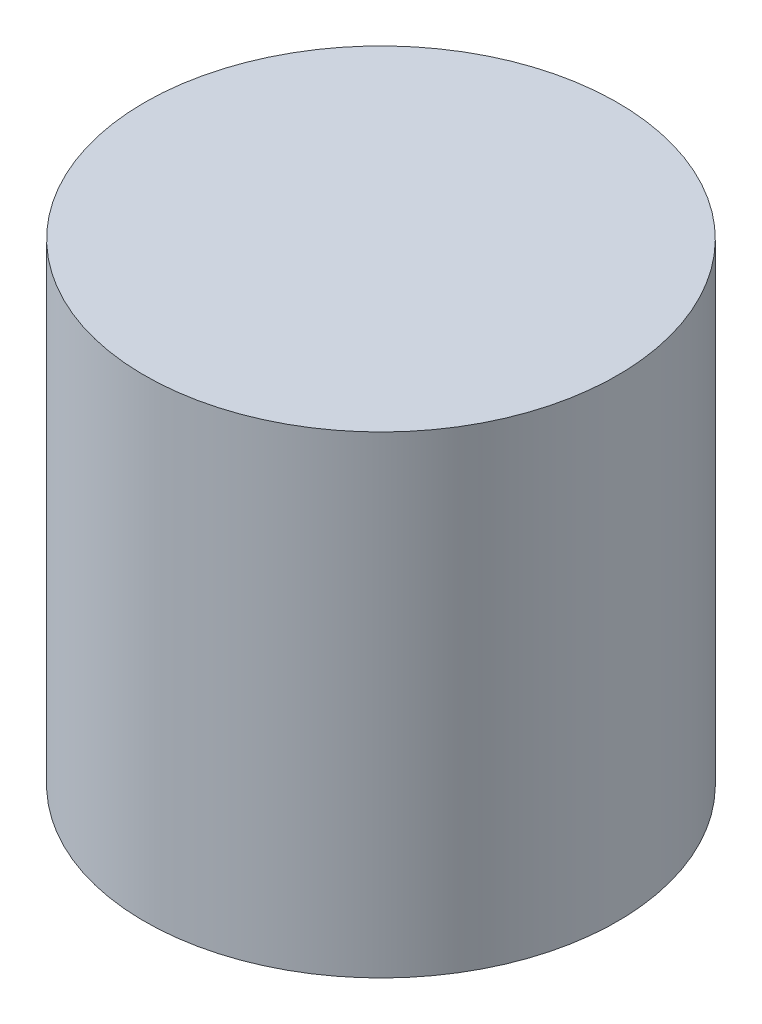
from build123d import *


with BuildPart() as part:
    # Sketch1 → Revolve1 (revolve)
    with BuildSketch(Plane.XY, mode=Mode.PRIVATE) as revolve1_sk:
        Polygon((50.8, 50.8), (0, 50.8), (0, 44.45), (44.45, 44.45), (44.45, -44.45), (0, -44.45), (0, -50.8), (50.8, -50.8), align=None)
    revolve(revolve1_sk.sketch.rotate(Axis((0, 50.8, 0), (0, -1, 0)), 180), axis=Axis((0, 50.8, 0), (0, -1, 0)))


solid = part.part
